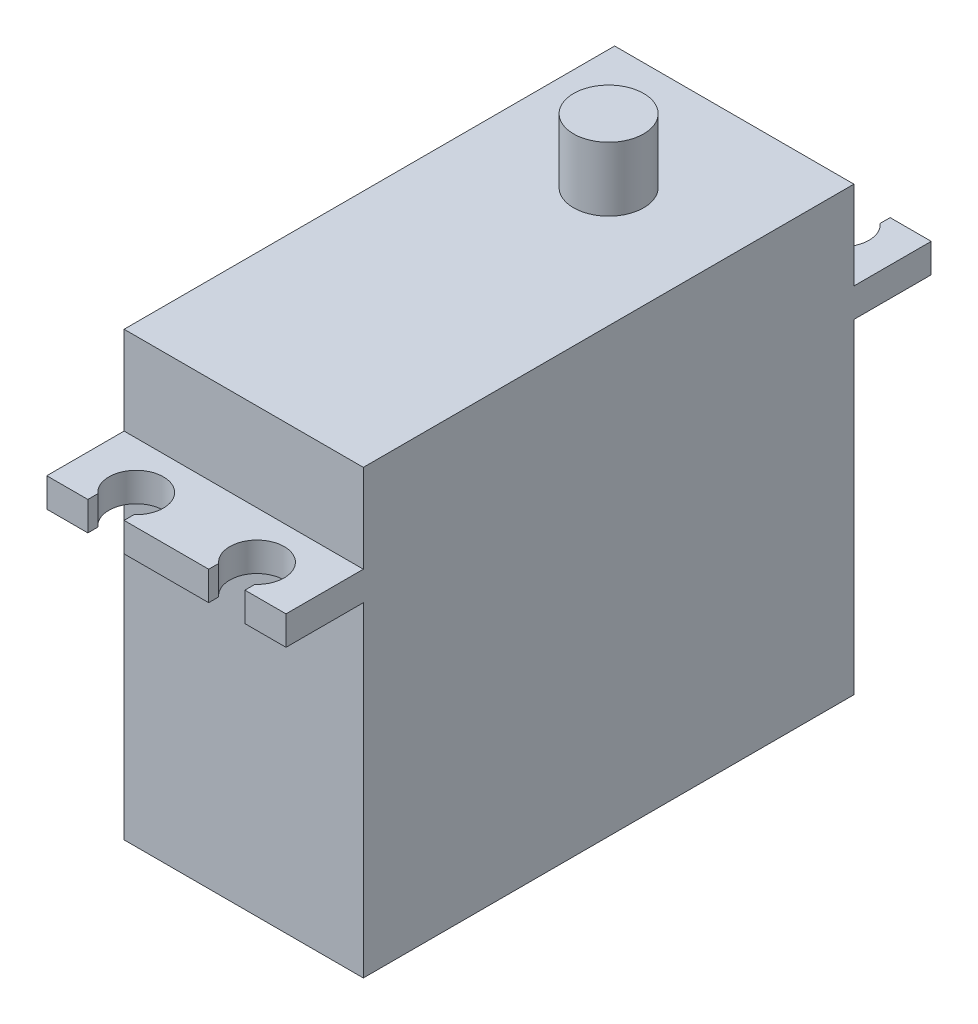
from build123d import *

# Parameters (mm, degrees)
SKETCH2_W           = 40.6
SKETCH2_H           = 36.6
SKETCH2_W_2         = 6.4
SKETCH2_H_2         = 2.4
SKETCH2_W_3         = 5.8
SKETCH2_H_3         = 5.3
BOSS_EXTRUDE1_DEPTH = 19.8
CUT_EXTRUDE1_DEPTH  = 5.3
CUT_EXTRUDE2_DEPTH  = 30.3


with BuildPart() as part:
    # Sketch2 → Boss-Extrude1 (new body)
    with BuildSketch(Plane(origin=(0, 0, 0), x_dir=(0, 0, -1), z_dir=(1, 0, 0))):
        Rectangle(SKETCH2_W, SKETCH2_H)
        with Locations((-23.5, 9.8)):
            Rectangle(SKETCH2_W_2, SKETCH2_H_2)
        with Locations((9.9, 20.95)):
            Rectangle(SKETCH2_W_3, SKETCH2_H_3)
        with Locations((23.5, 9.8)):
            Rectangle(SKETCH2_W_2, SKETCH2_H_2)
    extrude(amount=BOSS_EXTRUDE1_DEPTH)

    # Sketch3 → Cut-Extrude1 (cut)
    with BuildSketch(Plane(origin=(0, 18.3, 0), x_dir=(1, 0, 0), z_dir=(0, 1, 0))):
        with BuildLine():
            Line((9.9, 7), (12.8, 7))
            Line((12.8, 7), (12.8, 9.9))
            ThreePointArc((12.8, 9.9), (11.950609665, 7.849390335), (9.9, 7))
        make_face()
        with BuildLine():
            ThreePointArc((9.9, 12.8), (11.950609665, 11.950609665), (12.8, 9.9))
            Line((12.8, 9.9), (12.8, 12.8))
            Line((12.8, 12.8), (9.9, 12.8))
        make_face()
        with BuildLine():
            ThreePointArc((7, 9.9), (7.849390335, 11.950609665), (9.9, 12.8))
            Line((9.9, 12.8), (7, 12.8))
            Line((7, 12.8), (7, 9.9))
        make_face()
        with BuildLine():
            Line((7, 7), (9.9, 7))
            ThreePointArc((9.9, 7), (7.849390335, 7.849390335), (7, 9.9))
            Line((7, 9.9), (7, 7))
        make_face()
        Polygon((0, 7), (7, 7), (7, 9.9), (7, 12.8), (0, 12.8), align=None)
        Polygon((12.8, 7), (19.8, 7), (19.8, 12.8), (12.8, 12.8), (12.8, 9.9), align=None)
    extrude(amount=CUT_EXTRUDE1_DEPTH, mode=Mode.SUBTRACT)

    # Sketch4 → Cut-Extrude2 (cut, through all)
    with BuildSketch(Plane(origin=(0, 11, 0), x_dir=(1, 0, 0), z_dir=(0, 1, 0))):
        with BuildLine():
            ThreePointArc((16.4, 25.877050983), (14.9, 26.45), (13.4, 25.877050983))
            Line((13.4, 25.877050983), (16.4, 25.877050983))
        make_face()
        with BuildLine():
            Line((16.4, 25.877050983), (13.4, 25.877050983))
            ThreePointArc((13.4, 25.877050983), (13.981441346, 22.146040409), (17.15, 24.2))
            ThreePointArc((17.15, 24.2), (16.953959591, 25.118558654), (16.4, 25.877050983))
        make_face()
        with BuildLine():
            Line((16.4, 26.7), (13.4, 26.7))
            Line((13.4, 26.7), (13.4, 25.877050983))
            ThreePointArc((13.4, 25.877050983), (14.9, 26.45), (16.4, 25.877050983))
            Line((16.4, 25.877050983), (16.4, 26.7))
        make_face()
        with BuildLine():
            ThreePointArc((7.15, 24.2), (6.953959591, 25.118558654), (6.4, 25.877050983))
            Line((6.4, 25.877050983), (3.4, 25.877050983))
            ThreePointArc((3.4, 25.877050983), (3.981441346, 22.146040409), (7.15, 24.2))
        make_face()
        with BuildLine():
            Line((3.4, 25.877050983), (6.4, 25.877050983))
            ThreePointArc((6.4, 25.877050983), (4.9, 26.45), (3.4, 25.877050983))
        make_face()
        with BuildLine():
            Line((6.4, 25.877050983), (6.4, 26.7))
            Line((6.4, 26.7), (3.4, 26.7))
            Line((3.4, 26.7), (3.4, 25.877050983))
            ThreePointArc((3.4, 25.877050983), (4.9, 26.45), (6.4, 25.877050983))
        make_face()
        with BuildLine():
            ThreePointArc((13.4, -25.877050983), (14.9, -26.45), (16.4, -25.877050983))
            Line((16.4, -25.877050983), (13.4, -25.877050983))
        make_face()
        with BuildLine():
            Line((13.4, -25.877050983), (16.4, -25.877050983))
            ThreePointArc((16.4, -25.877050983), (16.953959591, -25.118558654), (17.15, -24.2))
            ThreePointArc((17.15, -24.2), (13.981441346, -22.146040409), (13.4, -25.877050983))
        make_face()
        with BuildLine():
            Line((13.4, -26.7), (16.4, -26.7))
            Line((16.4, -26.7), (16.4, -25.877050983))
            ThreePointArc((16.4, -25.877050983), (14.9, -26.45), (13.4, -25.877050983))
            Line((13.4, -25.877050983), (13.4, -26.7))
        make_face()
        with BuildLine():
            ThreePointArc((3.4, -25.877050983), (4.9, -26.45), (6.4, -25.877050983))
            Line((6.4, -25.877050983), (3.4, -25.877050983))
        make_face()
        with BuildLine():
            Line((3.4, -25.877050983), (6.4, -25.877050983))
            ThreePointArc((6.4, -25.877050983), (6.953959591, -25.118558654), (7.15, -24.2))
            ThreePointArc((7.15, -24.2), (3.981441346, -22.146040409), (3.4, -25.877050983))
        make_face()
        with BuildLine():
            Line((3.4, -26.7), (6.4, -26.7))
            Line((6.4, -26.7), (6.4, -25.877050983))
            ThreePointArc((6.4, -25.877050983), (4.9, -26.45), (3.4, -25.877050983))
            Line((3.4, -25.877050983), (3.4, -26.7))
        make_face()
    extrude(amount=-CUT_EXTRUDE2_DEPTH, mode=Mode.SUBTRACT)


solid = part.part
